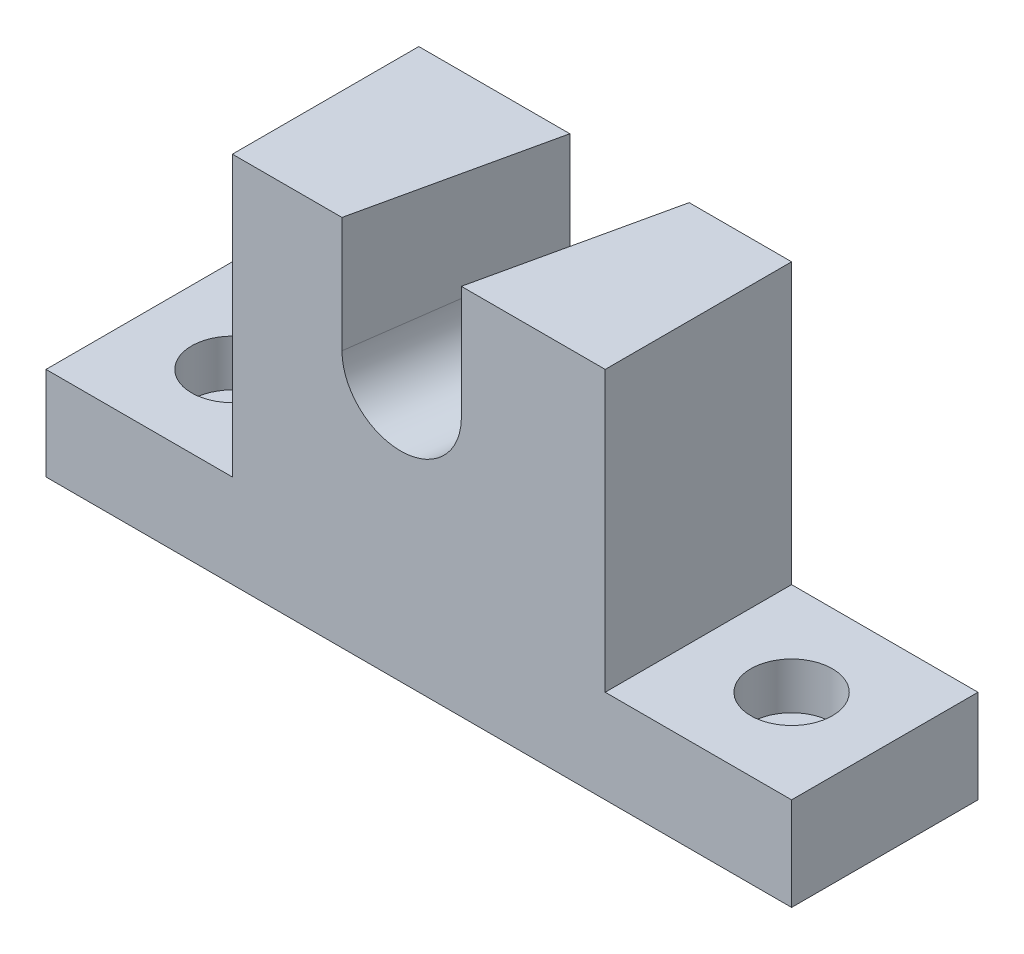
from build123d import *

# Parameters (mm, degrees)
BOSS_EXTRUDE1_DEPTH                              = 25.4
CBORE_FOR_1_4_SOCKET_HEAD_CAP_SCREW1_D           = 6.7564
CBORE_FOR_1_4_SOCKET_HEAD_CAP_SCREW1_CBORE_D     = 11.1125
CBORE_FOR_1_4_SOCKET_HEAD_CAP_SCREW1_CBORE_DEPTH = 6.35
SKETCH6_R                                        = 7.9375
CUT_EXTRUDE2_DEPTH                               = 93.898049386


with BuildPart() as part:
    # Sketch1 → Boss-Extrude1 (new body)
    with BuildSketch(Plane.XY):
        Polygon((25.4, 12.7), (50.8, 12.7), (50.8, 0), (-50.8, 0), (-50.8, 12.7), (-25.4, 12.7), (-25.4, 50.8), (25.4, 50.8), align=None)
    extrude(amount=BOSS_EXTRUDE1_DEPTH)

    # CBORE for 1/4 Socket Head Cap Screw1 (through all)
    with Locations(Plane(origin=(0, 12.7, 0), x_dir=(1, 0, 0), z_dir=(0, 1, 0))):
        with Locations((-38.1, -12.7), (38.1, -12.7)):
            CounterBoreHole(CBORE_FOR_1_4_SOCKET_HEAD_CAP_SCREW1_D / 2, CBORE_FOR_1_4_SOCKET_HEAD_CAP_SCREW1_CBORE_D / 2, CBORE_FOR_1_4_SOCKET_HEAD_CAP_SCREW1_CBORE_DEPTH)

    # Sketch6 → Cut-Extrude2 (cut, through all)
    with BuildSketch(Plane(origin=(-10.442463605, 32.464422505, 61.850379973), x_dir=(-0.9762276715802475, 0.026604535934103283, -0.21510865140374857), z_dir=(0.21650558359918726, 0.07280416213947143, -0.9735629852482811))):
        Circle(SKETCH6_R)
        with BuildLine():
            Line((-6.795136978, 42.915355356), (-7.934675442, 0.211735396))
            ThreePointArc((-7.934675442, 0.211735396), (0.105877117, 7.936793829), (7.9375, 0))
            ThreePointArc((7.9375, 0), (7.936793829, -0.105877117), (7.934675442, -0.211735396))
            Line((7.934675442, -0.211735396), (9.074213906, 42.491884564))
            Line((9.074213906, 42.491884564), (-6.795136978, 42.915355356))
        make_face()
    extrude(amount=CUT_EXTRUDE2_DEPTH, mode=Mode.SUBTRACT)


solid = part.part
